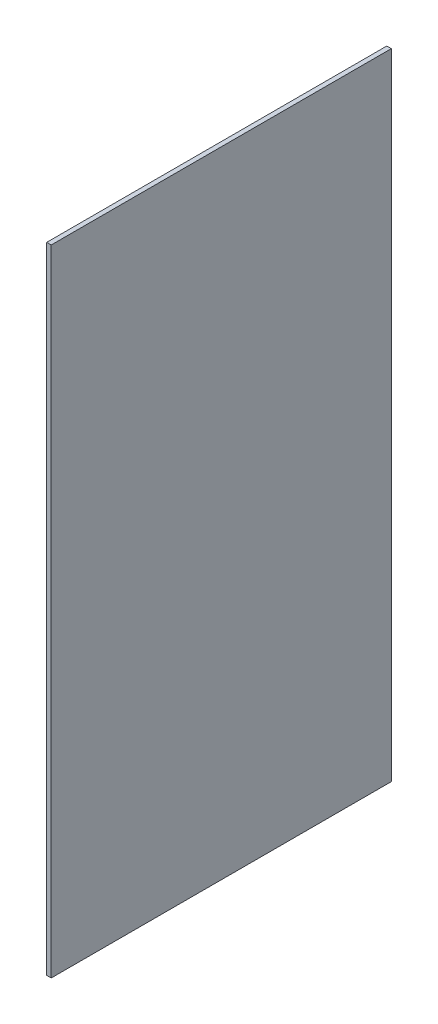
from build123d import *

# Parameters (mm, degrees)
SKETCH1_W           = 30
SKETCH1_H           = 56
BOSS_EXTRUDE1_DEPTH = 0.4


with BuildPart() as part:
    # Sketch1 → Boss-Extrude1 (new body)
    with BuildSketch(Plane(origin=(0, 0, 0), x_dir=(0, 0, -1), z_dir=(1, 0, 0))):
        Rectangle(SKETCH1_W, SKETCH1_H)
    extrude(amount=BOSS_EXTRUDE1_DEPTH)


solid = part.part
